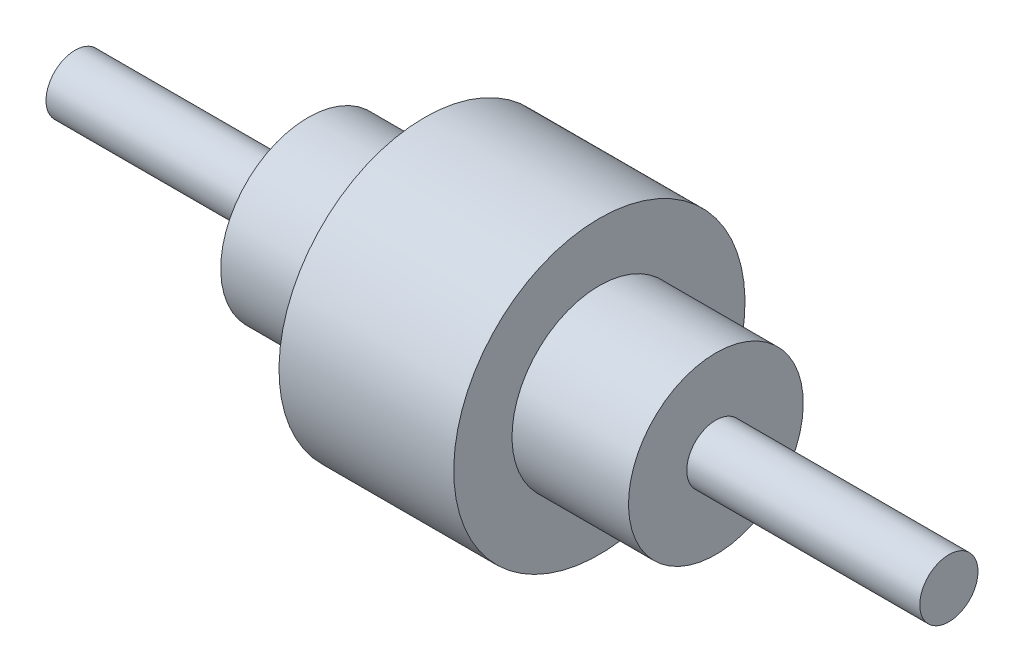
from build123d import *


with BuildPart() as part:
    # Sketch1 → Revolve1 (revolve)
    with BuildSketch(Plane.XY):
        Polygon((-30, 30), (-30, 50), (30, 50), (30, 30), (70, 30), (70, 10), (150, 10), (150, 0), (-150, 0), (-150, 10), (-70, 10), (-70, 30), align=None)
    revolve(axis=Axis((150, 0, 0), (-1, 0, 0)))


solid = part.part
